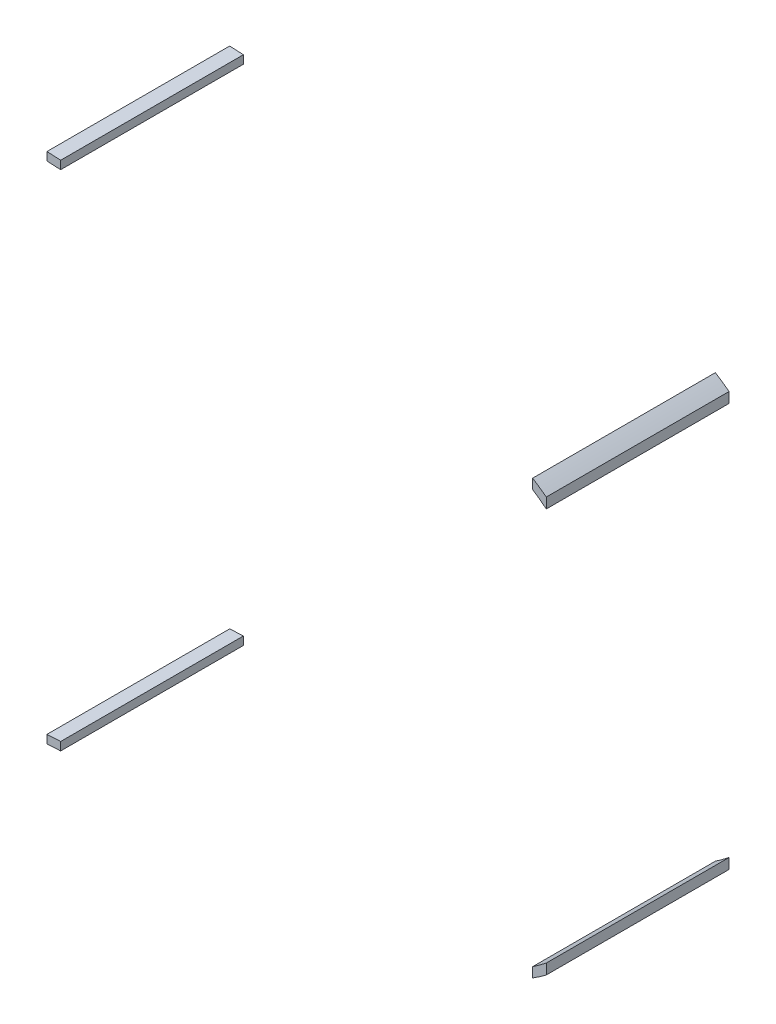
from build123d import *

# Parameters (mm, degrees)
BOSS_EXTRUDE1_DEPTH   = 40
BOSS_EXTRUDE1_2_DEPTH = 40
BOSS_EXTRUDE1_3_DEPTH = 40
BOSS_EXTRUDE1_4_DEPTH = 40


with BuildPart() as part:
    # Sketch2 → Boss-Extrude1 (new body)
    with BuildSketch(Plane.XY):
        with BuildLine():
            Line((123.102606631, -49.669698543), (123.102606631, -51.815505395))
            add(Edge.make_bspline(
                [(123.102606631, -51.815505395), (124.131312479, -51.169734334), (125.127954038, -50.474249112), (126.102606631, -49.744671044)],
                knots=[0.757538637, 0.757538637, 0.757538637, 0.757538637, 1, 1, 1, 1], degree=3))
            Line((126.102606631, -49.744671044), (126.102606631, -47.475709013))
            add(Edge.make_bspline(
                [(126.102606631, -47.475709013), (125.126920541, -48.242489739), (124.131030901, -48.97981269), (123.102606631, -49.669698543)],
                knots=[0, 0, 0, 0, 0.241038019, 0.241038019, 0.241038019, 0.241038019], degree=3))
        make_face()
    extrude(amount=BOSS_EXTRUDE1_DEPTH)


with BuildPart() as body_2:
    # Sketch2 → Boss-Extrude1 2 (new body)
    with BuildSketch(Plane.XY):
        with BuildLine():
            Line((123.102606631, 40.783442618), (123.102606631, 42.929249471))
            add(Edge.make_bspline(
                [(123.102606631, 42.929249471), (124.131312479, 42.28347841), (125.127954038, 41.587993188), (126.102606631, 40.85841512)],
                knots=[0.757538637, 0.757538637, 0.757538637, 0.757538637, 1, 1, 1, 1], degree=3))
            Line((126.102606631, 40.85841512), (126.102606633, 38.58945309))
            add(Edge.make_bspline(
                [(126.102606633, 38.58945309), (125.126920542, 39.356233816), (124.131030901, 40.093556766), (123.102606631, 40.783442618)],
                knots=[0, 0, 0, 0, 0.241038019, 0.241038019, 0.241038019, 0.241038019], degree=3))
        make_face()
    extrude(amount=BOSS_EXTRUDE1_2_DEPTH)


with BuildPart() as body_3:
    # Sketch2 → Boss-Extrude1 3 (new body)
    with BuildSketch(Plane.XY):
        Polygon((19.802606635, -58.631013225), (19.802606635, -60.43331094), (16.802606635, -60.584941464), (16.802606635, -58.782643749), align=None)
    extrude(amount=BOSS_EXTRUDE1_3_DEPTH)


with BuildPart() as body_4:
    # Sketch2 → Boss-Extrude1 4 (new body)
    with BuildSketch(Plane.XY):
        Polygon((19.802606635, 49.744757301), (16.802606635, 49.896387825), (16.802606635, 51.69868554), (19.802606635, 51.547055016), align=None)
    extrude(amount=BOSS_EXTRUDE1_4_DEPTH)


solid = Compound([part.part, body_2.part, body_3.part, body_4.part])
